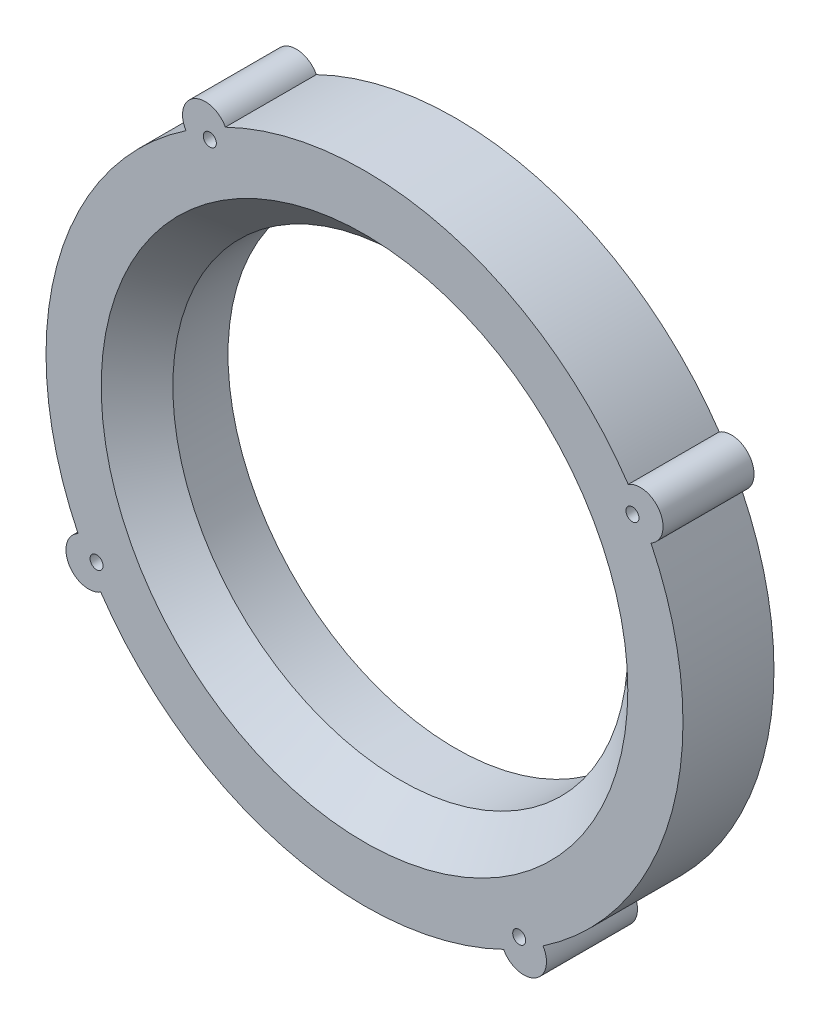
from build123d import *

# Parameters (mm, degrees)
SKETCH1_R           = 63.5
BOSS_EXTRUDE1_DEPTH = 25.4
CHAMFER1_SIZE       = 10
SKETCH3_R           = 1.8161
CUT_EXTRUDE1_DEPTH  = 26.4


with BuildPart() as part:
    # Sketch1 → Boss-Extrude1 (new body)
    with BuildSketch(Plane.XY):
        with BuildLine():
            ThreePointArc((49.832360156, -73.620281725), (85.870805957, -23.00901311), (79.966230688, 38.84085413))
            ThreePointArc((79.966230688, 38.84085413), (82.48891971, 47.625), (73.620281725, 49.832360156))
            ThreePointArc((73.620281725, 49.832360156), (23.00901311, 85.870805957), (-38.84085413, 79.966230688))
            ThreePointArc((-38.84085413, 79.966230688), (-47.625, 82.48891971), (-49.832360156, 73.620281725))
            ThreePointArc((-49.832360156, 73.620281725), (-85.870805957, 23.00901311), (-79.966230688, -38.84085413))
            ThreePointArc((-79.966230688, -38.84085413), (-82.48891971, -47.625), (-73.620281725, -49.832360156))
            ThreePointArc((-73.620281725, -49.832360156), (-23.00901311, -85.870805957), (38.84085413, -79.966230688))
            ThreePointArc((38.84085413, -79.966230688), (47.625, -82.48891971), (49.832360156, -73.620281725))
        make_face()
        Circle(SKETCH1_R, mode=Mode.SUBTRACT)
    extrude(amount=BOSS_EXTRUDE1_DEPTH)

    # Chamfer1
    chamfer1_edges = [part.edges().sort_by_distance(p)[0] for p in [
        (-63.5, 0, 25.4),
    ]]
    chamfer(chamfer1_edges, length=CHAMFER1_SIZE)

    # Sketch3 → Cut-Extrude1 (cut, through all)
    with BuildSketch(Plane.XY.offset(25.4)):
        with Locations((74.789953871, 43.18)):
            Circle(SKETCH3_R)
        with Locations((43.18, -74.789953871)):
            Circle(SKETCH3_R)
        with Locations((-74.789953871, -43.18)):
            Circle(SKETCH3_R)
        with Locations((-43.18, 74.789953871)):
            Circle(SKETCH3_R)
    extrude(amount=-CUT_EXTRUDE1_DEPTH, mode=Mode.SUBTRACT)


solid = part.part
